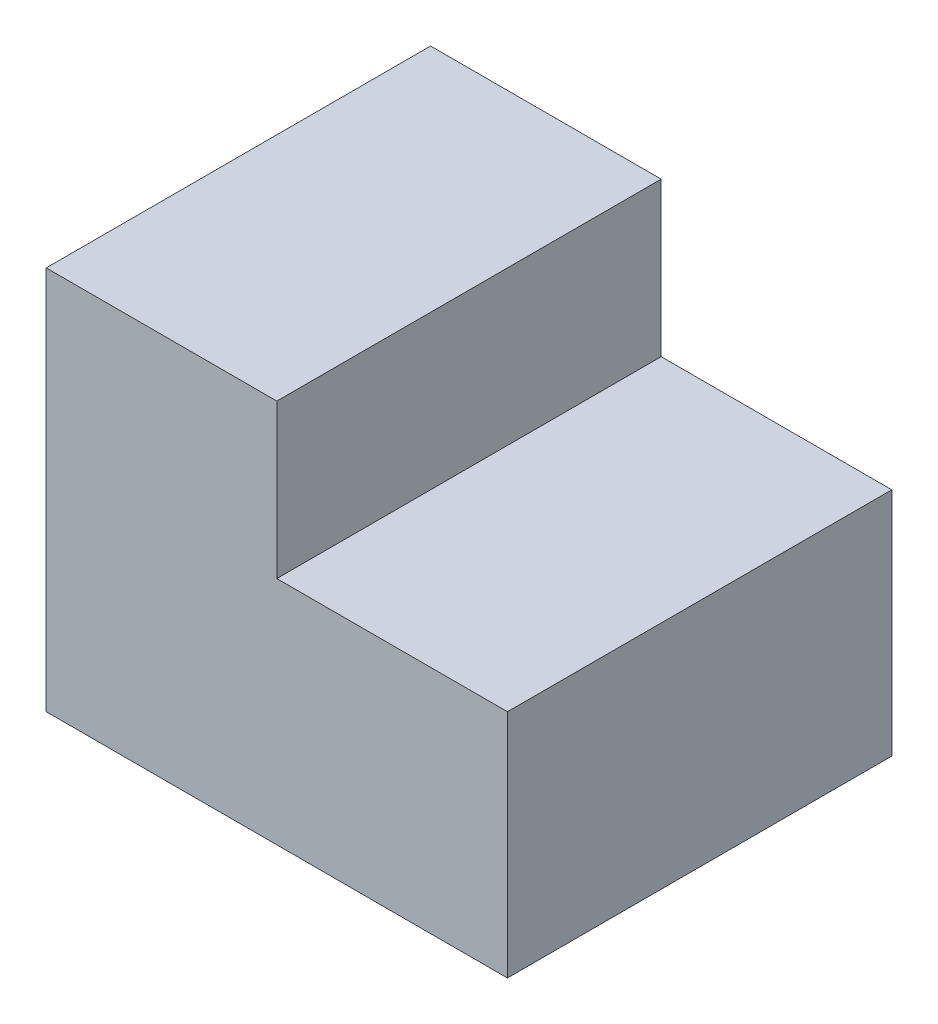
from build123d import *

# Parameters (mm, degrees)
BOSS_EXTRUDE1_DEPTH = 25


with BuildPart() as part:
    # Sketch1 → Boss-Extrude1 (new body)
    with BuildSketch(Plane.XY):
        Polygon((-30, 25), (-15, 25), (-15, 15), (0, 15), (0, 0), (-30, 0), align=None)
    extrude(amount=BOSS_EXTRUDE1_DEPTH)


solid = part.part
